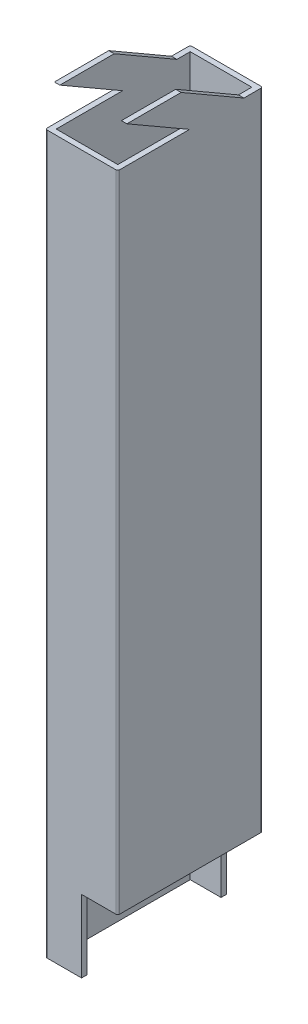
from build123d import *

# Parameters (mm, degrees)
SKETCH1_W           = 17
SKETCH1_H           = 37
BOSS_EXTRUDE1_DEPTH = 208
SKETCH2_W           = 10
SKETCH2_H           = 20
CUT_EXTRUDE1_DEPTH  = 40
CUT_EXTRUDE2_DEPTH  = 40


with BuildPart() as part:
    # Sketch1 → Boss-Extrude1 (new body)
    with BuildSketch(Plane(origin=(0, 0, 0), x_dir=(1, 0, 0), z_dir=(0, 1, 0))):
        with BuildLine():
            Line((0.5, 0), (19.5, 0))
            ThreePointArc((19.5, 0), (19.853553391, 0.146446609), (20, 0.5))
            Line((20, 0.5), (20, 39.5))
            ThreePointArc((20, 39.5), (19.853553391, 39.853553391), (19.5, 40))
            Line((19.5, 40), (0.5, 40))
            ThreePointArc((0.5, 40), (0.146446609, 39.853553391), (0, 39.5))
            Line((0, 39.5), (0, 0.5))
            ThreePointArc((0, 0.5), (0.146446609, 0.146446609), (0.5, 0))
        make_face()
        with Locations((10, 20)):
            Rectangle(SKETCH1_W, SKETCH1_H, mode=Mode.SUBTRACT)
    extrude(amount=BOSS_EXTRUDE1_DEPTH)

    # Sketch2 → Cut-Extrude1 (cut)
    with BuildSketch(Plane.XY):
        with Locations((15, 10)):
            Rectangle(SKETCH2_W, SKETCH2_H)
    extrude(amount=-CUT_EXTRUDE1_DEPTH, mode=Mode.SUBTRACT)

    # Sketch3 → Cut-Extrude2 (cut)
    with BuildSketch(Plane(origin=(0, 0, 0), x_dir=(0, 0, -1), z_dir=(1, 0, 0))):
        Polygon((0, 208), (0, 198), (19.820508076, 198), (2.5, 208), align=None)
        Polygon((17.5, 208), (34.820508076, 198), (40, 198), (40, 208), align=None)
    extrude(amount=CUT_EXTRUDE2_DEPTH, mode=Mode.SUBTRACT)


solid = part.part
